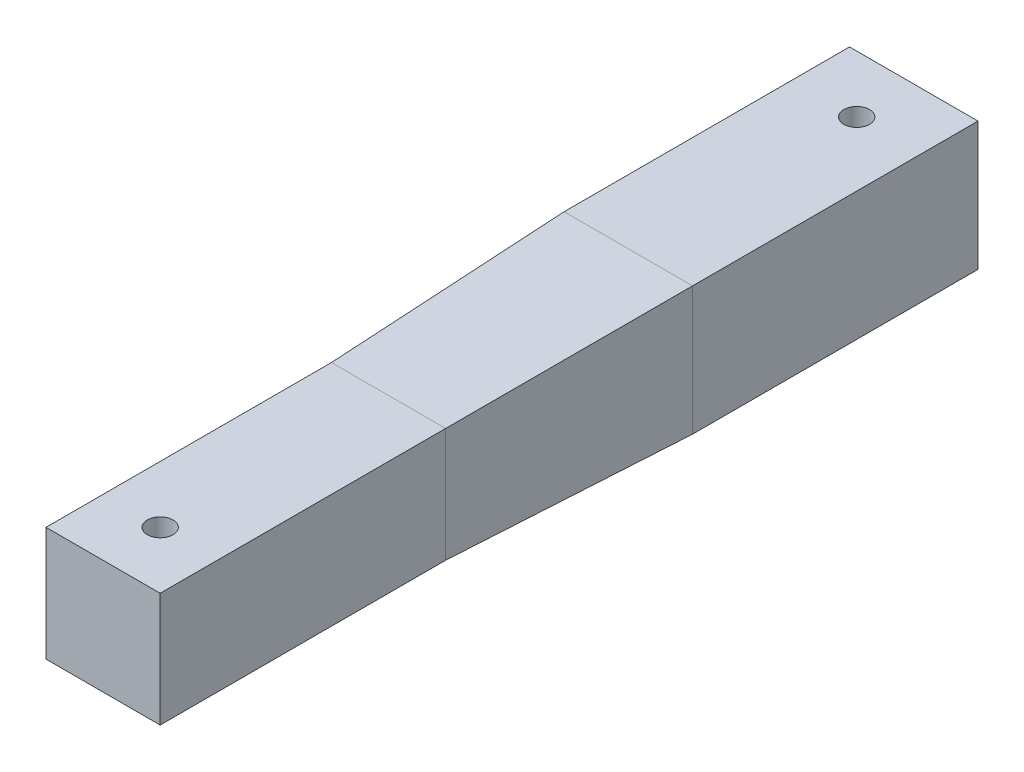
from build123d import *

# Parameters (mm, degrees)
ESQUISSE1_W             = 20
ESQUISSE1_H             = 20
BOSS_EXTRU_1_DEPTH      = 50
ESQUISSE2_W             = 22.5
ESQUISSE2_H             = 22.5
BOSS_EXTRU_2_DEPTH      = 50
ESQUISSE5_W             = 22.5
ESQUISSE5_H             = 22.5
ESQUISSE4_W             = 20
ESQUISSE4_H             = 20
ENL_V_MAT_EXTRU_1_REACH = 24.5
ESQUISSE6_R             = 2.25
ENL_V_MAT_EXTRU_2_REACH = 23.25
ESQUISSE7_R             = 2.25


with BuildPart() as part:
    # Esquisse1 → Boss.-Extru.1 (new body)
    with BuildSketch(Plane.XY):
        with Locations((-32.865009747, 8)):
            Rectangle(ESQUISSE1_W, ESQUISSE1_H)
    extrude(amount=BOSS_EXTRU_1_DEPTH)



with BuildPart() as body_2:
    # Esquisse2 → Boss.-Extru.2 (new body)
    with BuildSketch(Plane(origin=(0, 0, -92), x_dir=(-1, 0, 0), z_dir=(0, 0, -1))):
        with Locations((32.865009747, 8)):
            Rectangle(ESQUISSE2_W, ESQUISSE2_H)
    extrude(amount=-BOSS_EXTRU_2_DEPTH)


with BuildPart() as part_1:
    add(part.part)

    add(body_2.part)  # Lissage1 merges body 2
    # Esquisse5 → Lissage1 section 0
    with BuildSketch(Plane.XY.offset(-42)):
        with Locations((-32.865009747, 8)):
            Rectangle(ESQUISSE5_W, ESQUISSE5_H)
    # Esquisse4 → Lissage1 section 1
    with BuildSketch(Plane(origin=(0, 0, 0), x_dir=(-1, 0, 0), z_dir=(0, 0, -1))):
        with Locations((32.865009747, 8)):
            Rectangle(ESQUISSE4_W, ESQUISSE4_H)
    loft()

    # Esquisse6 → Enlèv. mat.-Extru.1 (cut, up to next)
    with BuildSketch(Plane(origin=(0, 19.25, 0), x_dir=(1, 0, 0), z_dir=(0, 1, 0)), mode=Mode.PRIVATE) as enl_v_mat_extru_1_sk1:
        with Locations((-32.865009747, 82)):
            Circle(ESQUISSE6_R)
    enl_v_mat_extru_1_tool1 = extrude(enl_v_mat_extru_1_sk1.sketch, amount=-ENL_V_MAT_EXTRU_1_REACH, mode=Mode.PRIVATE) & part_1.part
    add(enl_v_mat_extru_1_tool1.solids().sort_by_distance((-32.86501, 19.25, -82))[0], mode=Mode.SUBTRACT)

    # Esquisse7 → Enlèv. mat.-Extru.2 (cut, up to next)
    with BuildSketch(Plane.XZ.offset(2), mode=Mode.PRIVATE) as enl_v_mat_extru_2_sk1:
        with Locations((-32.865009747, 40)):
            Circle(ESQUISSE7_R)
    enl_v_mat_extru_2_tool1 = extrude(enl_v_mat_extru_2_sk1.sketch, amount=-ENL_V_MAT_EXTRU_2_REACH, mode=Mode.PRIVATE) & part_1.part
    add(enl_v_mat_extru_2_tool1.solids().sort_by_distance((-32.86501, -2, 40))[0], mode=Mode.SUBTRACT)


solid = part_1.part
